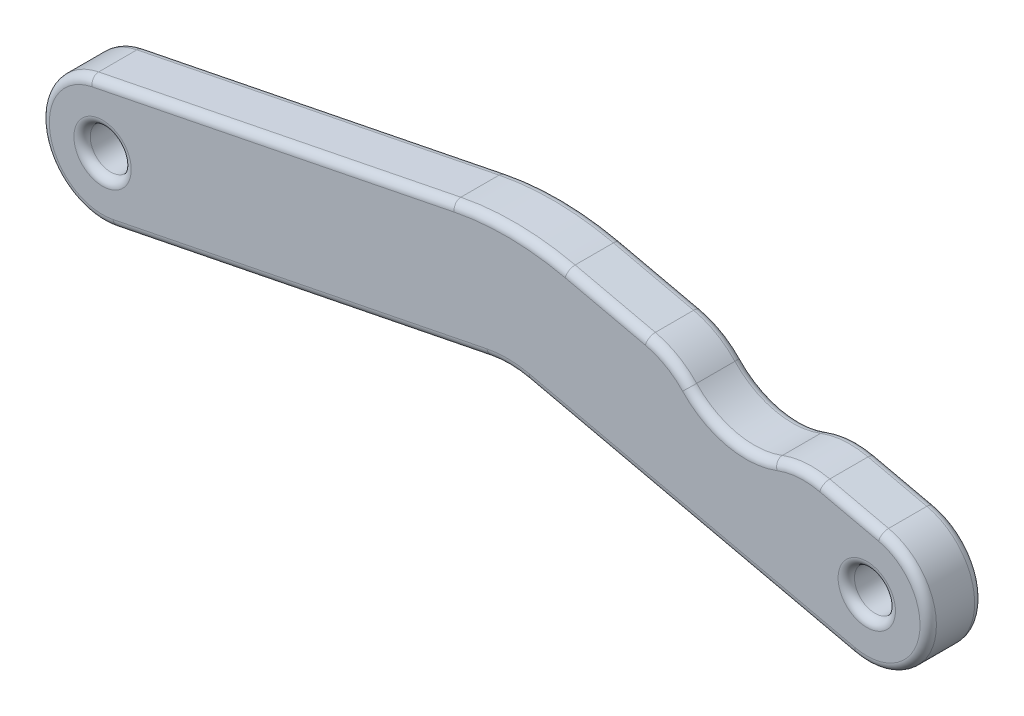
from build123d import *

# Parameters (mm, degrees)
SKETCH1_R               = 0.75
BOSS_EXTRUDE1_DEPTH     = 2
SKETCH3_OUTSIDE_W       = 41.059
SKETCH3_OUTSIDE_H       = 13.072
CUT_EXTRUDE4_DEPTH      = 3
SKETCH4_R               = 0.75
BOSS_EXTRUDE2_DEPTH     = 2
SKETCH6_R               = 1
CUT_EXTRUDE6_DEPTH      = 3
CUT_EXTRUDE6_DEPTH_BACK = 1
FILLET1_R               = 0.3


with BuildPart() as part:
    # Sketch1 → Boss-Extrude1 (new body)
    with BuildSketch(Plane.XY):
        with BuildLine():
            Line((0, 2.25), (27.987244, 2.25))
            ThreePointArc((27.987244, 2.25), (30.237244, 0), (27.987244, -2.25))
            Line((27.987244, -2.25), (0, -2.25))
            ThreePointArc((0, -2.25), (-2.25, 0), (0, 2.25))
        make_face()
        Circle(SKETCH1_R, mode=Mode.SUBTRACT)
        with Locations((27.987244, 0)):
            Circle(SKETCH1_R, mode=Mode.SUBTRACT)
    extrude(amount=BOSS_EXTRUDE1_DEPTH)

    # Sketch3 outside → Cut-Extrude4 (cut, through all)
    with BuildSketch(Plane.XY):
        with Locations((13.9935, 0)):
            Rectangle(SKETCH3_OUTSIDE_W, SKETCH3_OUTSIDE_H)
        with BuildLine():
            Line((0.442179, -2.206123), (14.1398, 0.539327))
            ThreePointArc((14.1398, 0.539327), (14.859952, 0.606014), (15.578104, 0.520435))
            Line((15.578104, 0.520435), (27.487273, -2.193748))
            ThreePointArc((27.487273, -2.193748), (30.180992, -0.49997), (28.487214, 2.193748))
            Line((28.487214, 2.193748), (17.009193, 4.809669))
            ThreePointArc((17.009193, 4.809669), (14.918439, 5.058816), (12.821862, 4.864669))
            Line((12.821862, 4.864669), (-0.442179, 2.206123))
            ThreePointArc((-0.442179, 2.206123), (-2.206123, -0.442179), (0.442179, -2.206123))
        make_face(mode=Mode.SUBTRACT)
    extrude(amount=CUT_EXTRUDE4_DEPTH, mode=Mode.SUBTRACT)

    # Sketch4 → Boss-Extrude2 (add)
    with BuildSketch(Plane.XY.offset(2)):
        with BuildLine():
            Line((12.821862, 4.864669), (-0.442179, 2.206123))
            ThreePointArc((-0.442179, 2.206123), (-2.206123, -0.442179), (0.442179, -2.206123))
            Line((0.442179, -2.206123), (14.1398, 0.539327))
            ThreePointArc((14.1398, 0.539327), (14.859952, 0.606014), (15.578104, 0.520435))
            Line((15.578104, 0.520435), (27.487273, -2.193748))
            ThreePointArc((27.487273, -2.193748), (30.180992, -0.49997), (28.487214, 2.193748))
            Line((28.487214, 2.193748), (17.009193, 4.809669))
            ThreePointArc((17.009193, 4.809669), (14.918439, 5.058816), (12.821862, 4.864669))
        make_face()
        with Locations((27.987244, 0)):
            Circle(SKETCH4_R, mode=Mode.SUBTRACT)
        Circle(SKETCH4_R, mode=Mode.SUBTRACT)
    extrude(amount=-BOSS_EXTRUDE2_DEPTH)

    # Sketch6 → Cut-Extrude6 (cut, two sides)
    with BuildSketch(Plane.XY) as cut_extrude6_sk:
        with BuildLine():
            Line((26.333572, 2.684578), (28.487214, 2.193748))
            Line((28.487214, 2.193748), (29.127227, 6.389132))
            Line((29.127227, 6.389132), (19.031577, 7.177512))
            Line((19.031577, 7.177512), (18.760134, 4.410617))
            Line((18.760134, 4.410617), (19.946022, 4.140345))
            ThreePointArc((19.946022, 4.140345), (20.765816, 3.821217), (21.457794, 3.278011))
            ThreePointArc((21.457794, 3.278011), (22.919174, 2.44442), (24.597437, 2.562464))
            ThreePointArc((24.597437, 2.562464), (25.456455, 2.752187), (26.333572, 2.684578))
        make_face()
        with Locations((23.56358, 5.271917)):
            Circle(SKETCH6_R, mode=Mode.SUBTRACT)
    extrude(amount=CUT_EXTRUDE6_DEPTH, mode=Mode.SUBTRACT)
    extrude(cut_extrude6_sk.sketch, amount=-CUT_EXTRUDE6_DEPTH_BACK, mode=Mode.SUBTRACT)

    # Fillet1
    fillet1_edges = [part.edges().sort_by_distance(p)[0] for p in [
        (27.237244, 0, 0),
        (-0.75, 0, 0),
        (7.290989, -0.833398, 0),
        (14.859952, 0.606014, 0),
        (21.532689, -0.836656, 0),
        (30.223137, -0.251562, 0),
        (17.884663, 4.610143, 2),
        (17.884663, 4.610143, 0),
        (27.410393, 2.439163, 2),
        (27.410393, 2.439163, 0),
        (14.918439, 5.058816, 2),
        (14.918439, 5.058816, 0),
        (6.189842, 3.535396, 2),
        (6.189842, 3.535396, 0),
        (-2.239004, -0.222175, 0),
        (27.237244, 0, 2),
        (-0.75, 0, 2),
        (30.223137, -0.251562, 2),
        (21.532689, -0.836656, 2),
        (14.859952, 0.606014, 2),
        (7.290989, -0.833398, 2),
        (-2.239004, -0.222175, 2),
        (20.765816, 3.821217, 0),
        (25.456455, 2.752187, 0),
        (22.919174, 2.44442, 0),
        (20.765816, 3.821217, 2),
        (22.919174, 2.44442, 2),
        (25.456455, 2.752187, 2),
    ]]
    fillet(fillet1_edges, radius=FILLET1_R)


solid = part.part
